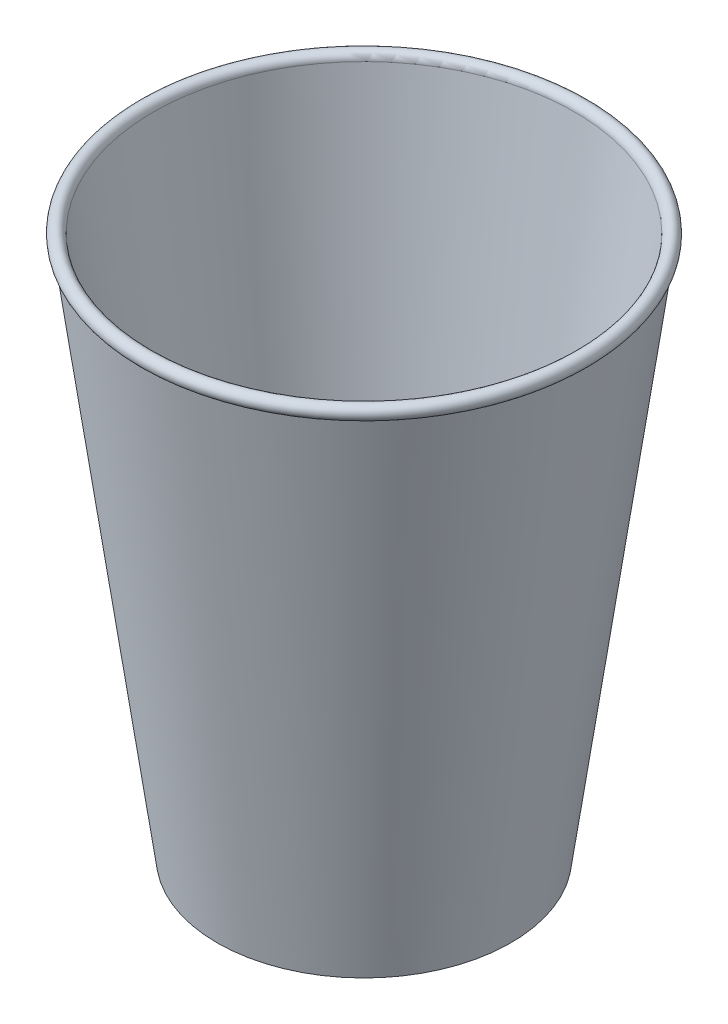
from build123d import *


with BuildPart() as part:
    # Sketch2 → Revolve1 (revolve)
    with BuildSketch(Plane.XY):
        with BuildLine():
            Line((0, -60.673498533), (-29.5, -60.673498533))
            Line((-29.5, -60.673498533), (-44.129854748, 46.612102954))
            ThreePointArc((-44.129854748, 46.612102954), (-44.484955407, 49.081768332), (-42.287077377, 47.900804437))
            Line((-42.287077377, 47.900804437), (-27.754217881, -58.673498533))
            Line((-27.754217881, -58.673498533), (0, -58.673498533))
            Line((0, -58.673498533), (0, -60.673498533))
        make_face()
    revolve(axis=Axis((0, 29.188203924, 0), (0, -1, 0)))


solid = part.part
